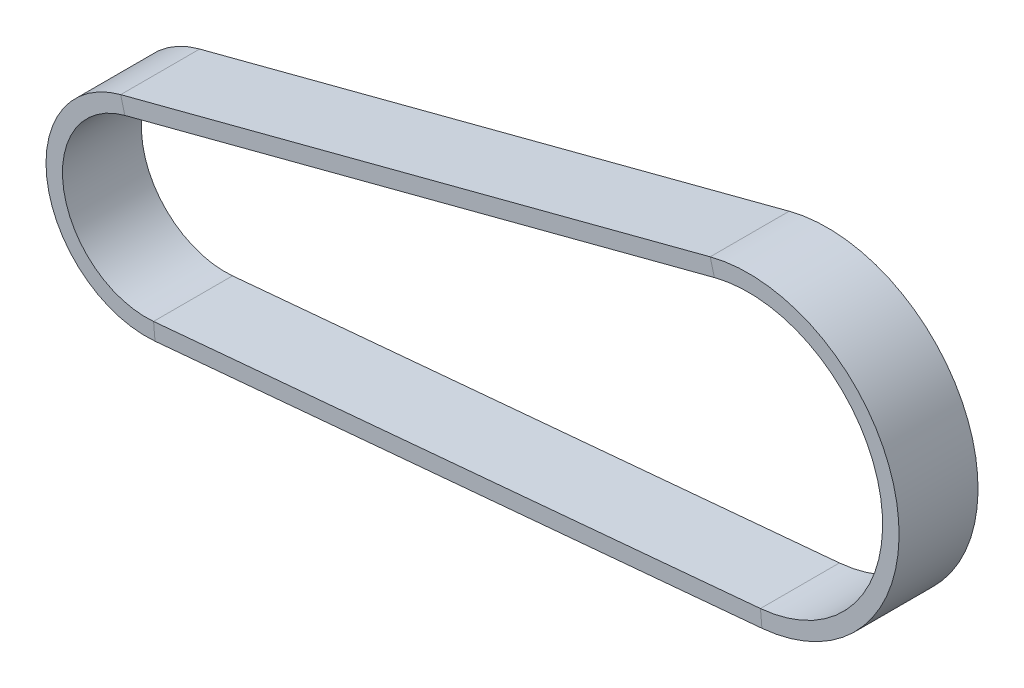
from build123d import *

# Parameters (mm, degrees)
SKETCH3_W = 6
SKETCH3_H = 1.25


with BuildPart() as part:
    # Sweep1: sweep along a path in Sketch2
    with BuildLine(Plane.XY) as sweep1_path:
        Line((0.917678109, -10.15863509), (-45.195380767, -14.324248316))
        ThreePointArc((-45.195380767, -14.324248316), (-52.021836512, -9.093399143), (-47.374658016, -1.856962649))
        Line((-47.374658016, -1.856962649), (-2.582893221, 9.867556061))
        ThreePointArc((-2.582893221, 9.867556061), (10.04765238, 1.756326183), (0.917678109, -10.15863509))
    # Sketch3 → Sweep1 (sweep)
    with BuildSketch(Plane(origin=(0.917678109, -10.15863509, 0), x_dir=(0, 0, 1), z_dir=(-0.995944617, -0.089968442, 0))):
        with Locations((0, -0.625)):
            Rectangle(SKETCH3_W, SKETCH3_H)
    sweep(path=sweep1_path.line)


solid = part.part
